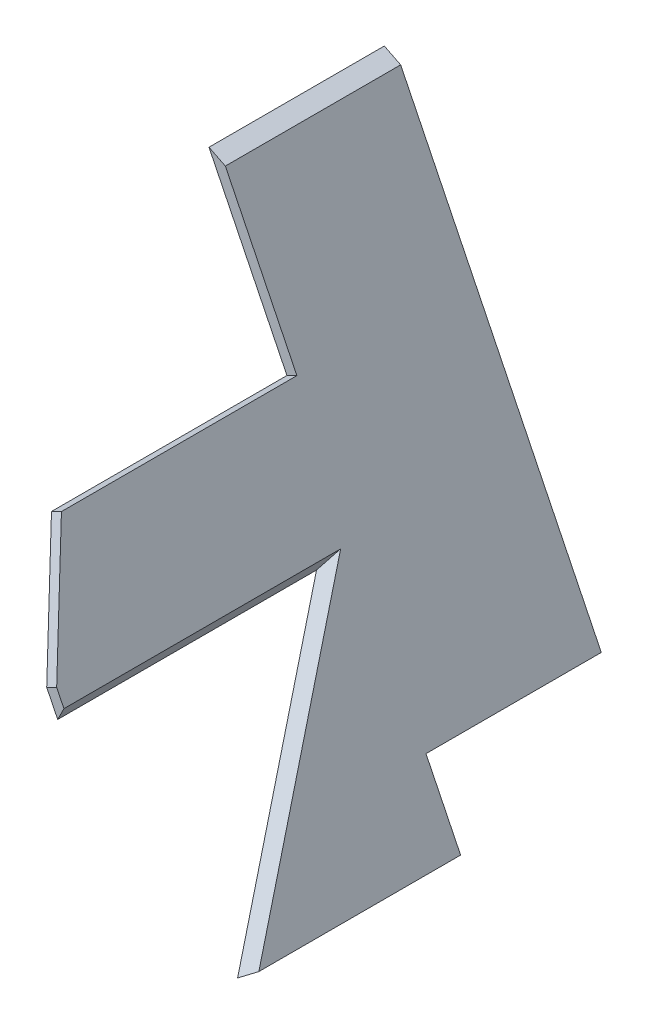
from build123d import *

# Parameters (mm, degrees)
BOSS_EXTRUDE1_DEPTH = 208.295834
CUT_EXTRUDE1_DEPTH  = 233.9651465
CUT_EXTRUDE3_DEPTH  = 106.39675924
BOSS_EXTRUDE2_DEPTH = 79


with BuildPart() as part:
    # Sketch2 → Boss-Extrude1 (new body)
    with BuildSketch(Plane.XY.offset(133.323635178)):
        Polygon((-552.096326618, 302.497295421), (-547.608266937, 304.701228339), (-659.457001573, 532.468503885), (-662.259879772, 526.832889814), align=None)
    extrude(amount=BOSS_EXTRUDE1_DEPTH)

    # Sketch3 → Cut-Extrude1 (cut, through all)
    with BuildSketch(Plane(origin=(56.456528708, 113.514460847, 99.05047984), x_dir=(-0.935748975, 0.239556806, 0.258817295), z_dir=(-0.350913088, -0.705564279, -0.615661475))):
        Polygon((641.877398582, 324.891396181), (520.568005211, 262.71812893), (690.075774021, -224.74438404), (811.385167392, -162.571116789), align=None)
    extrude(amount=-CUT_EXTRUDE1_DEPTH, mode=Mode.SUBTRACT)

    # Sketch5 → Cut-Extrude3 (cut, through all)
    with BuildSketch(Plane(origin=(-325.143320908, -159.666786774, 0), x_dir=(0, 0, 1), z_dir=(-0.897611936, -0.440786584, 0))):
        Polygon((263.823635178, 620.544936833), (263.823635178, 631.781992675), (239.430319814, 682.249402309), (133.323635178, 682.249402309), (133.323635178, 768.6298834), (341.619468978, 768.6298834), (341.619468978, 620.544936833), align=None)
    extrude(amount=-CUT_EXTRUDE3_DEPTH, mode=Mode.SUBTRACT)

    # Sketch6 → Boss-Extrude2 (add)
    with BuildSketch(Plane(origin=(0, 0, 133.323635178), x_dir=(-1, 0, 0), z_dir=(0, 0, -1))):
        Polygon((567.701533334, 334.275530817), (563.213473653, 336.479463735), (653.626470855, 520.595288681), (660.996902767, 524.260980239), align=None)
    extrude(amount=BOSS_EXTRUDE2_DEPTH)


solid = part.part
